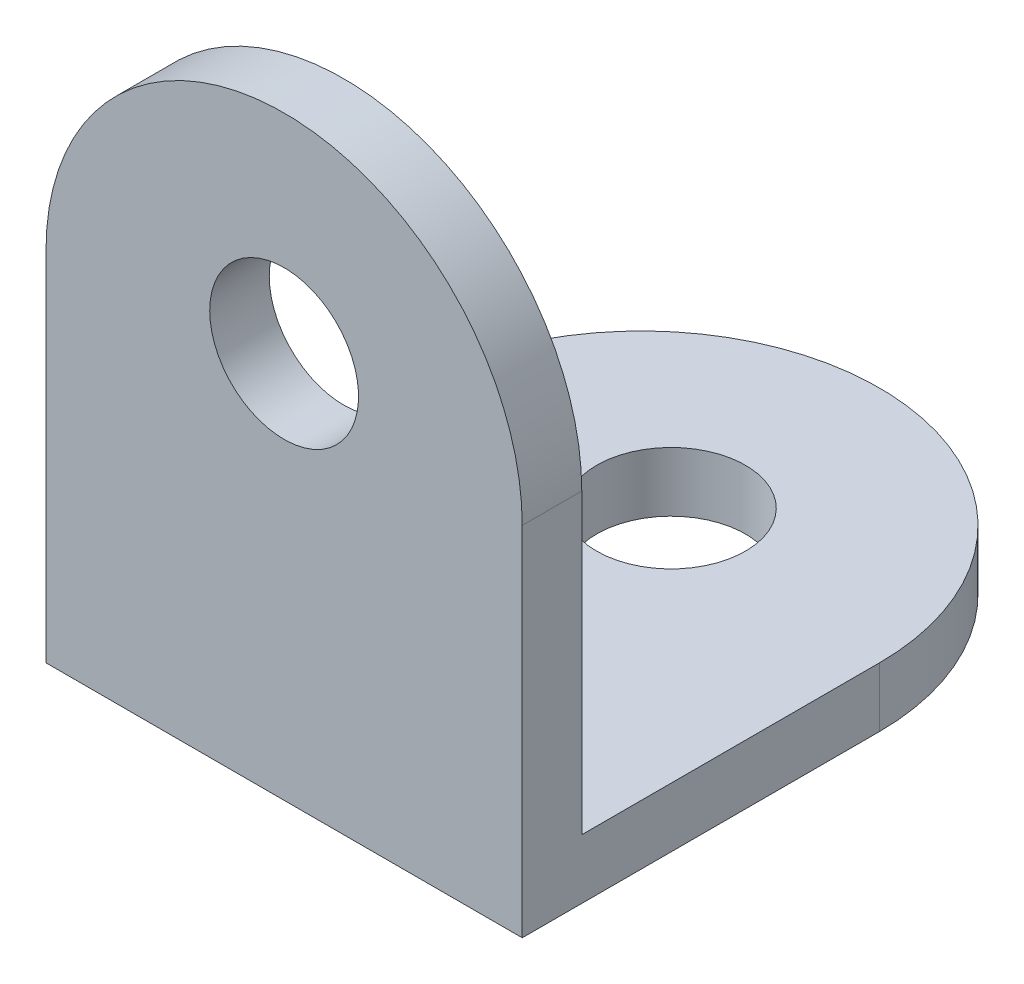
from build123d import *

# Parameters (mm, degrees)
EXTRUDE_1_DEPTH     = 2
SKETCH_2_W          = 16
SKETCH_2_H          = 2
EXTRUDE_2_DEPTH     = 10
EXTRUDE_3_DEPTH     = 2
SKETCH_4_R          = 2.5
CUT_EXTRUDE_1_DEPTH = 3
SKETCH_5_R          = 2.5
CUT_EXTRUDE_2_DEPTH = 3


with BuildPart() as part:
    # 草图1 → 凸台-拉伸1 (new body)
    with BuildSketch(Plane(origin=(0, 0, 0), x_dir=(1, 0, 0), z_dir=(0, 1, 0))):
        with BuildLine():
            Line((8, 1.423853667), (-8, 1.423853667))
            Line((-8, 1.423853667), (-8, 13.423853667))
            ThreePointArc((-8, 13.423853667), (0, 21.423853667), (8, 13.423853667))
            Line((8, 13.423853667), (8, 1.423853667))
        make_face()
    extrude(amount=EXTRUDE_1_DEPTH)

    # 草图2 → 凸台-拉伸2 (add)
    with BuildSketch(Plane(origin=(0, 2, 0), x_dir=(1, 0, 0), z_dir=(0, 1, 0))):
        with Locations((0, 2.423853667)):
            Rectangle(SKETCH_2_W, SKETCH_2_H)
    extrude(amount=EXTRUDE_2_DEPTH)

    # 草图3 → 凸台-拉伸3 (add)
    with BuildSketch(Plane(origin=(0, 0, -3.423853667), x_dir=(-1, 0, 0), z_dir=(0, 0, -1))):
        with BuildLine():
            Line((-8, 12), (8, 12))
            ThreePointArc((8, 12), (0, 20), (-8, 12))
        make_face()
    extrude(amount=-EXTRUDE_3_DEPTH)

    # 草图4 → 切除-拉伸1 (cut, through all)
    with BuildSketch(Plane(origin=(0, 2, 0), x_dir=(1, 0, 0), z_dir=(0, 1, 0))):
        with Locations((0, 14.423853667)):
            Circle(SKETCH_4_R)
    extrude(amount=-CUT_EXTRUDE_1_DEPTH, mode=Mode.SUBTRACT)

    # 草图5 → 切除-拉伸2 (cut, through all)
    with BuildSketch(Plane(origin=(0, 0, -3.423853667), x_dir=(-1, 0, 0), z_dir=(0, 0, -1))):
        with Locations((0, 13)):
            Circle(SKETCH_5_R)
    extrude(amount=-CUT_EXTRUDE_2_DEPTH, mode=Mode.SUBTRACT)


solid = part.part
